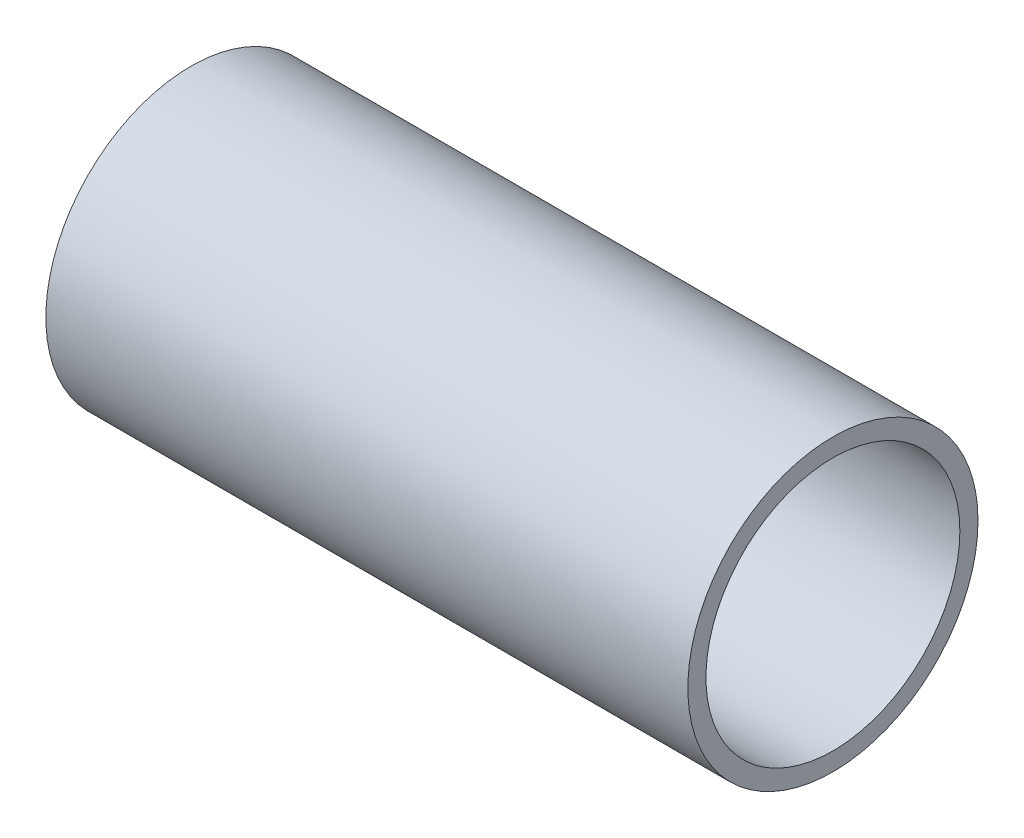
from build123d import *

# Parameters (mm, degrees)
CROQUIS1_R              = 8
CROQUIS1_R_2            = 7
SALIENTE_EXTRUIR1_DEPTH = 35.4


with BuildPart() as part:
    # Croquis1 → Saliente-Extruir1 (new body)
    with BuildSketch(Plane(origin=(0, 0, 0), x_dir=(0, 0, -1), z_dir=(1, 0, 0))):
        Circle(CROQUIS1_R)
        Circle(CROQUIS1_R_2, mode=Mode.SUBTRACT)
    extrude(amount=SALIENTE_EXTRUIR1_DEPTH)


solid = part.part
